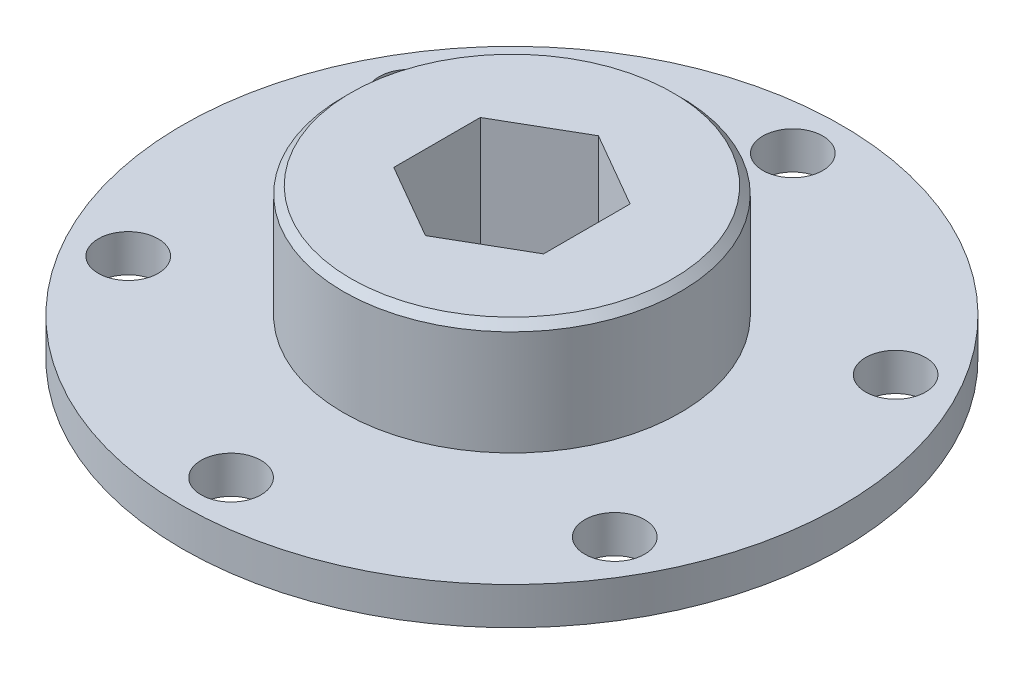
from build123d import *

# Parameters (mm, degrees)
SKETCH1_R               = 27.94
BOSS_EXTRUDE1_DEPTH     = 3.175
SKETCH2_R               = 14.2875
BOSS_EXTRUDE2_DEPTH     = 9.525
CHAMFER1_SIZE           = 0.635
CUT_EXTRUDE2_DEPTH      = 1
CUT_EXTRUDE2_DEPTH_BACK = 13.7
SKETCH4_R               = 2.54
CUT_EXTRUDE3_DEPTH      = 13.7


with BuildPart() as part:
    # Sketch1 → Boss-Extrude1 (new body)
    with BuildSketch(Plane(origin=(0, 0, 0), x_dir=(1, 0, 0), z_dir=(0, 1, 0))):
        Circle(SKETCH1_R)
    extrude(amount=BOSS_EXTRUDE1_DEPTH)

    # Sketch2 → Boss-Extrude2 (add)
    with BuildSketch(Plane(origin=(0, 3.175, 0), x_dir=(1, 0, 0), z_dir=(0, 1, 0))):
        Circle(SKETCH2_R)
    extrude(amount=BOSS_EXTRUDE2_DEPTH)

    # Chamfer1
    chamfer1_edges = [part.edges().sort_by_distance(p)[0] for p in [
        (-14.2875, 12.7, 0),
    ]]
    chamfer(chamfer1_edges, length=CHAMFER1_SIZE)

    # Sketch3 → Cut-Extrude2 (cut, two sides)
    with BuildSketch(Plane(origin=(0, 12.7, 0), x_dir=(1, 0, 0), z_dir=(0, 1, 0))) as cut_extrude2_sk:
        Polygon((6.35, 3.666174209), (0, 7.332348419), (-6.35, 3.666174209), (-6.35, -3.666174209), (0, -7.332348419), (6.35, -3.666174209), align=None)
    extrude(amount=CUT_EXTRUDE2_DEPTH, mode=Mode.SUBTRACT)
    extrude(cut_extrude2_sk.sketch, amount=-CUT_EXTRUDE2_DEPTH_BACK, mode=Mode.SUBTRACT)

    # Sketch4 → Cut-Extrude3 (cut, through all)
    with BuildSketch(Plane.XZ):
        with Locations((0, 23.8125)):
            Circle(SKETCH4_R)
        with Locations((20.622229928, 11.90625)):
            Circle(SKETCH4_R)
        with Locations((20.622229928, -11.90625)):
            Circle(SKETCH4_R)
        with Locations((0, -23.8125)):
            Circle(SKETCH4_R)
        with Locations((-20.622229928, -11.90625)):
            Circle(SKETCH4_R)
        with Locations((-20.622229928, 11.90625)):
            Circle(SKETCH4_R)
    extrude(amount=-CUT_EXTRUDE3_DEPTH, mode=Mode.SUBTRACT)


solid = part.part
